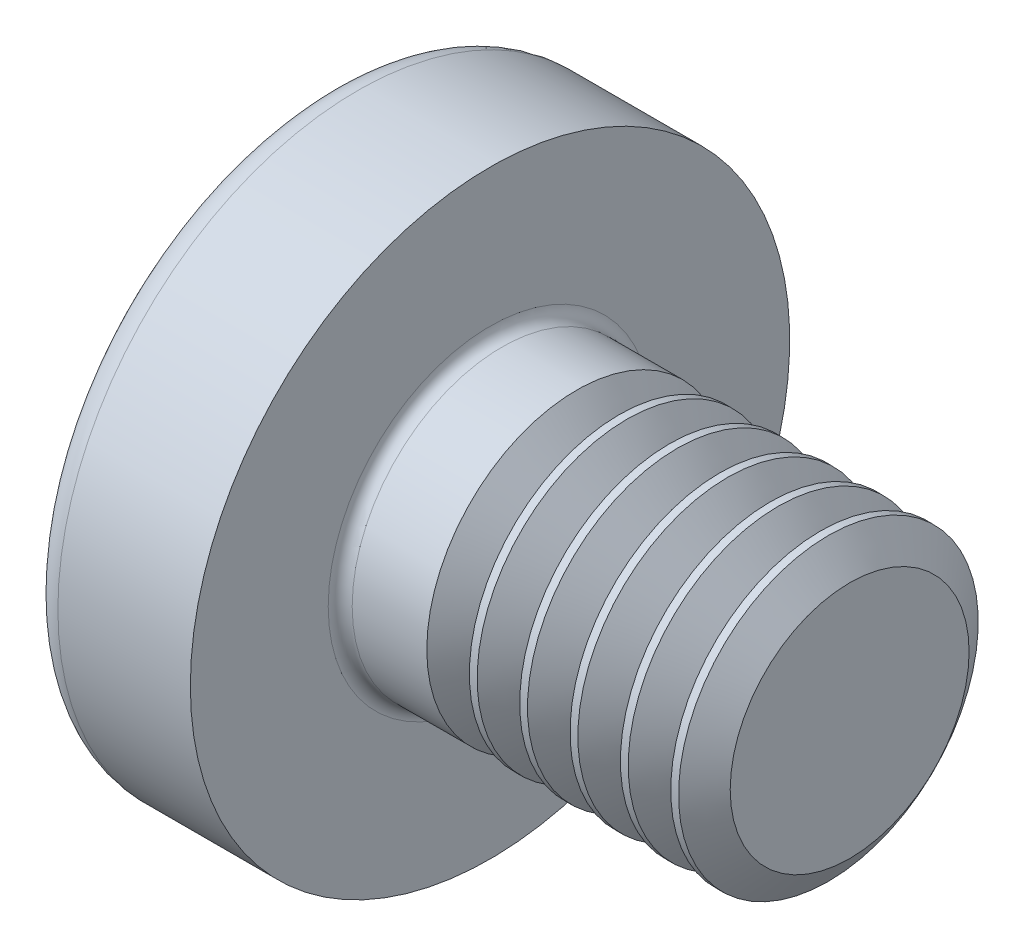
from build123d import *

# Parameters (mm, degrees)
FILLET1_R       = 0.1
SKETCH3_W       = 0.74
SKETCH3_H       = 2.6
SKETCH4_W       = 0.74
SKETCH4_H       = 1.104255426
RECPAT_COUNT    = 2
RECPAT_ANGLE    = 90
THDSCHPAT_COUNT = 6
THDSCHPAT_PITCH = 0.42


with BuildPart() as part:
    # BodySke → Base-Revolve (revolve)
    with BuildSketch(Plane.XY, mode=Mode.PRIVATE) as base_revolve_sk:
        with BuildLine():
            Line((2.1, 1.25), (2.1, 2.5))
            Line((2.1, 2.5), (0.99500416, 2.5))
            ThreePointArc((0.99500416, 2.5), (0.88781572, 2.474733878), (0.803195915, 2.404255319))
            ThreePointArc((0.803195915, 2.404255319), (0.206109099, 1.267435138), (0, 0))
            Line((0, 0), (5.1, 0))
            Line((5.1, 0), (5.1, 1.25))
            Line((5.1, 1.25), (2.1, 1.25))
        make_face()
    revolve(base_revolve_sk.sketch.rotate(Axis((-25.4, 0, 0), (1, 0, 0)), 90), axis=Axis((-25.4, 0, 0), (1, 0, 0)))  # turned: the seam where the file's is

    # Fillet1
    fillet1_edges = [part.edges().sort_by_distance(p)[0] for p in [
        (2.1, 0, -1.25),
    ]]
    fillet(fillet1_edges, radius=FILLET1_R)

    # Sketch3 → Recess section 0
    with BuildSketch(Plane(origin=(0, 0, 0), x_dir=(0, 0, -1), z_dir=(1, 0, 0))):
        Rectangle(SKETCH3_W, SKETCH3_H)
    # Sketch4 → Recess section 1
    with BuildSketch(Plane(origin=(1.5, 0, 0), x_dir=(0, 0, -1), z_dir=(1, 0, 0))):
        Rectangle(SKETCH4_W, SKETCH4_H)
    recess = loft(mode=Mode.SUBTRACT)

    # RecPat: Recess ×2 about axis
    recpat_axis = Axis((0, 0, 0), (1, 0, 0))
    for i in range(1, RECPAT_COUNT):
        add(recess.rotate(recpat_axis, i * RECPAT_ANGLE / (RECPAT_COUNT - 1)), mode=Mode.SUBTRACT)

    # RecCorSke → RecessCore (revolve, cut)
    with BuildSketch(Plane.XY, mode=Mode.PRIVATE) as recesscore_sk:
        Polygon((0, 0), (0, 0.660890218), (1.5, 0.556), (1.680655351, 0), align=None)
    revolve(recesscore_sk.sketch.rotate(Axis((-3.175, 0, 0), (1, 0, 0)), 90), axis=Axis((-3.175, 0, 0), (1, 0, 0)), mode=Mode.SUBTRACT)  # turned: the seam where the file's is

    # ThdSchSke → ThreadSchematic (revolve, cut)
    with BuildSketch(Plane.XY, mode=Mode.PRIVATE) as threadschematic_sk:
        Polygon((3, -0.9965), (2.822497389, -1.25), (2.822497389, -1.5625), (3.177502611, -1.5625), (3.177502611, -1.25), align=None)
    threadschematic = revolve(threadschematic_sk.sketch.rotate(Axis((-3.175, 0, 0), (1, 0, 0)), 270), axis=Axis((-3.175, 0, 0), (1, 0, 0)), mode=Mode.SUBTRACT)  # turned: the seam where the file's is

    # ThdSchPat: ThreadSchematic ×6
    with Locations(*[(i * THDSCHPAT_PITCH, 0, 0) for i in range(1, THDSCHPAT_COUNT)]):
        add(threadschematic, mode=Mode.SUBTRACT)


solid = part.part
